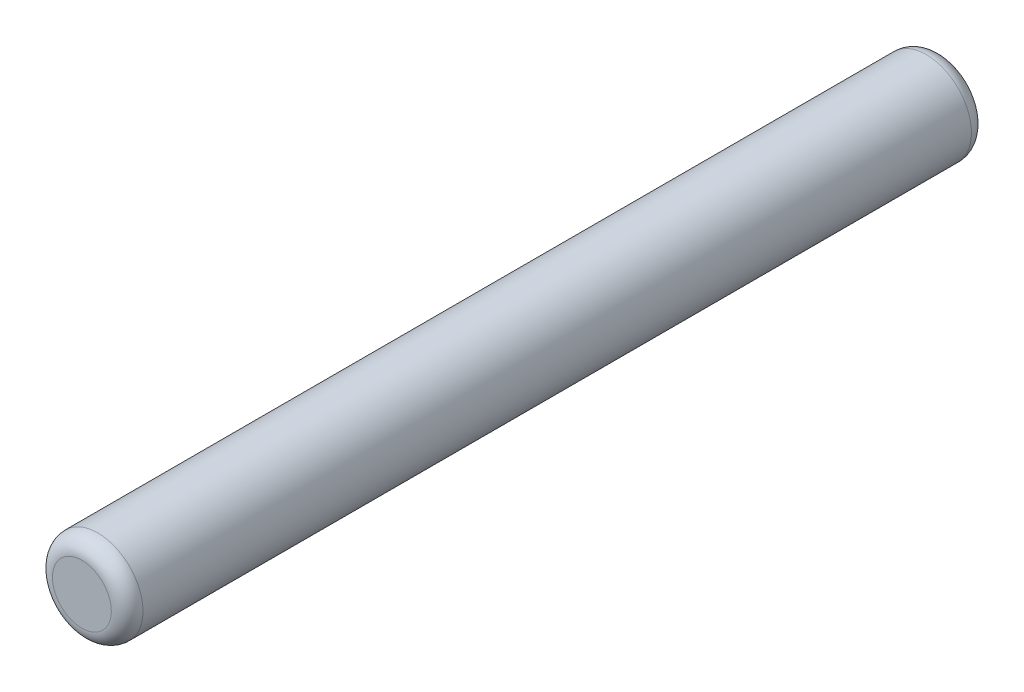
from build123d import *

# Parameters (mm, degrees)
SKETCH1_R           = 1
BOSS_EXTRUDE1_DEPTH = 9.5
FILLET1_R           = 0.35


with BuildPart() as part:
    # Sketch1 → Boss-Extrude1 (new body, symmetric)
    with BuildSketch(Plane.XY):
        Circle(SKETCH1_R)
    extrude(amount=BOSS_EXTRUDE1_DEPTH, both=True)

    # Fillet1
    fillet1_edges = [part.edges().sort_by_distance(p)[0] for p in [
        (-1, 0, -9.5),
        (-1, 0, 9.5),
    ]]
    fillet(fillet1_edges, radius=FILLET1_R)


solid = part.part
